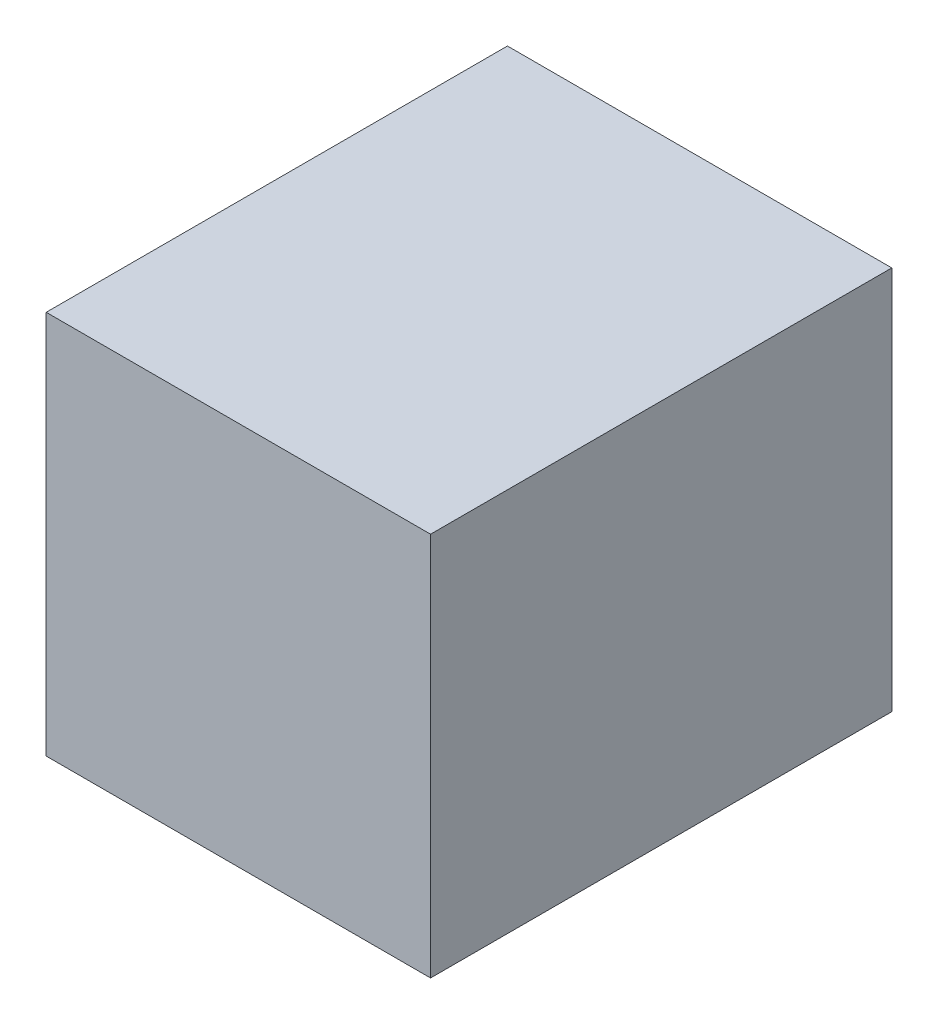
from build123d import *

# Parameters (mm, degrees)
SKETCH1_W           = 250
SKETCH1_H           = 300
BOSS_EXTRUDE1_DEPTH = 250


with BuildPart() as part:
    # Sketch1 → Boss-Extrude1 (new body)
    with BuildSketch(Plane(origin=(0, 0, 0), x_dir=(1, 0, 0), z_dir=(0, 1, 0))):
        Rectangle(SKETCH1_W, SKETCH1_H)
    extrude(amount=BOSS_EXTRUDE1_DEPTH)


solid = part.part
